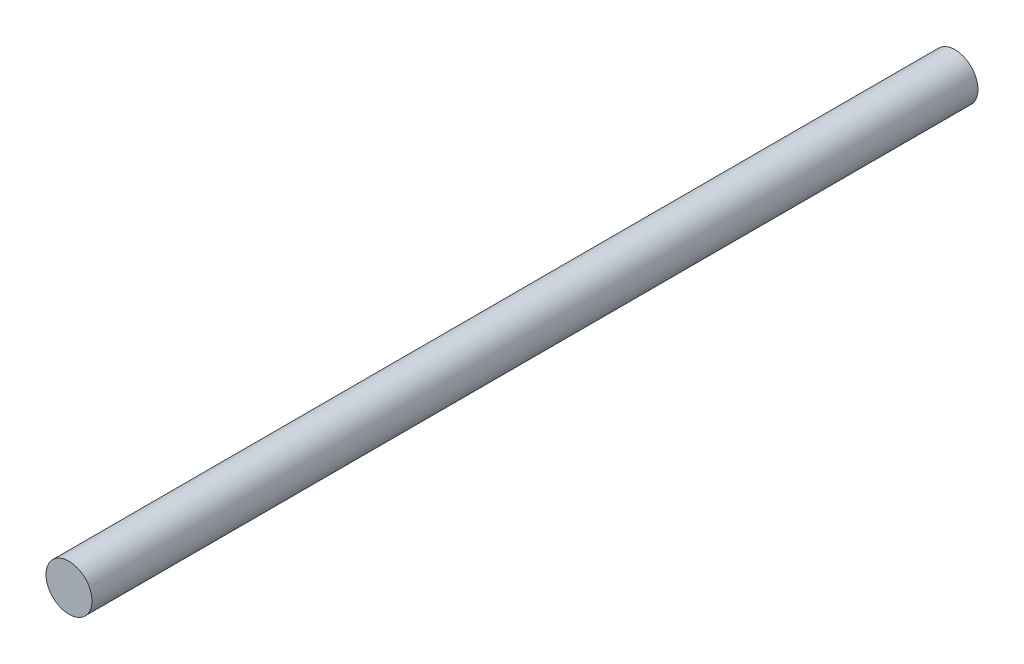
from build123d import *

# Parameters (mm, degrees)
SKETCH_1_R      = 4
EXTRUDE_1_DEPTH = 154


with BuildPart() as part:
    # 草图1 → 凸台-拉伸1 (new body)
    with BuildSketch(Plane.XY):
        Circle(SKETCH_1_R)
    extrude(amount=EXTRUDE_1_DEPTH)


solid = part.part
